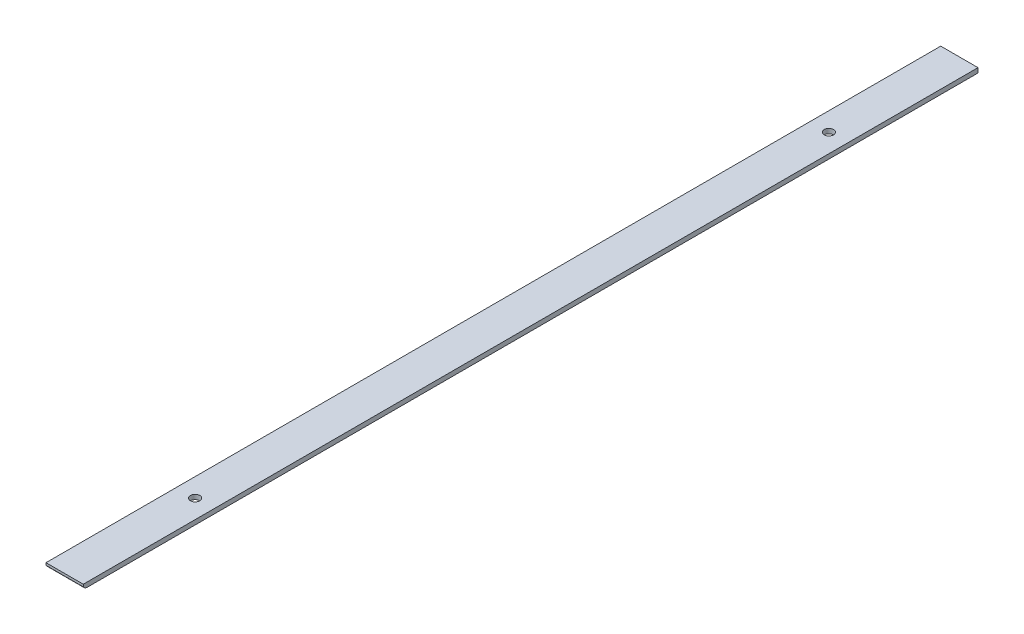
from build123d import *

# Parameters (mm, degrees)
BOSS_EXTRUDE1_DEPTH = 25.4
SKETCH2_R           = 3.175
CUT_EXTRUDE1_DEPTH  = 4.175


with BuildPart() as part:
    # Sketch1 → Boss-Extrude1 (new body)
    with BuildSketch(Plane(origin=(0, 0, 0), x_dir=(0, 0, -1), z_dir=(1, 0, 0))):
        with BuildLine():
            Line((-23.584545256, 0), (-23.584545256, -1.5875))
            ThreePointArc((-23.584545256, -1.5875), (-22.422414599, -2.749630657), (-20.834914599, -3.175))
            Line((-20.834914599, -3.175), (586.015454744, -3.175))
            Line((586.015454744, -3.175), (586.015454744, 0))
            Line((586.015454744, 0), (-23.584545256, 0))
        make_face()
    extrude(amount=BOSS_EXTRUDE1_DEPTH)

    # Sketch2 → Cut-Extrude1 (cut, through all)
    with BuildSketch(Plane(origin=(0, 0, 0), x_dir=(1, 0, 0), z_dir=(0, 1, 0))):
        with Locations((12.7, 65.315454744)):
            Circle(SKETCH2_R)
        with Locations((12.7, 497.115454744)):
            Circle(SKETCH2_R)
    extrude(amount=-CUT_EXTRUDE1_DEPTH, mode=Mode.SUBTRACT)


solid = part.part
